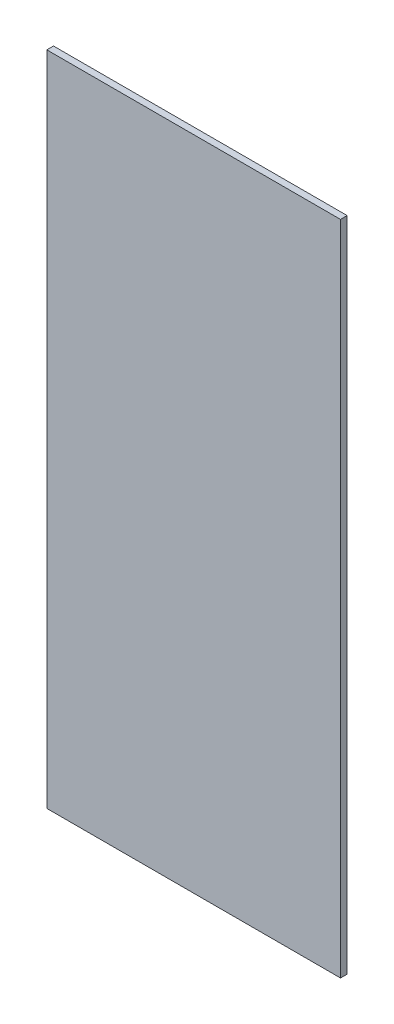
from build123d import *

# Parameters (mm, degrees)
SKETCH1_W      = 176.4
SKETCH1_H      = 394.6
EXTRUDE1_DEPTH = 4


with BuildPart() as part:
    # Sketch1 → Extrude1 (new body)
    with BuildSketch(Plane.XY):
        with Locations((0, -197.3)):
            Rectangle(SKETCH1_W, SKETCH1_H)
    extrude(amount=EXTRUDE1_DEPTH)


solid = part.part
